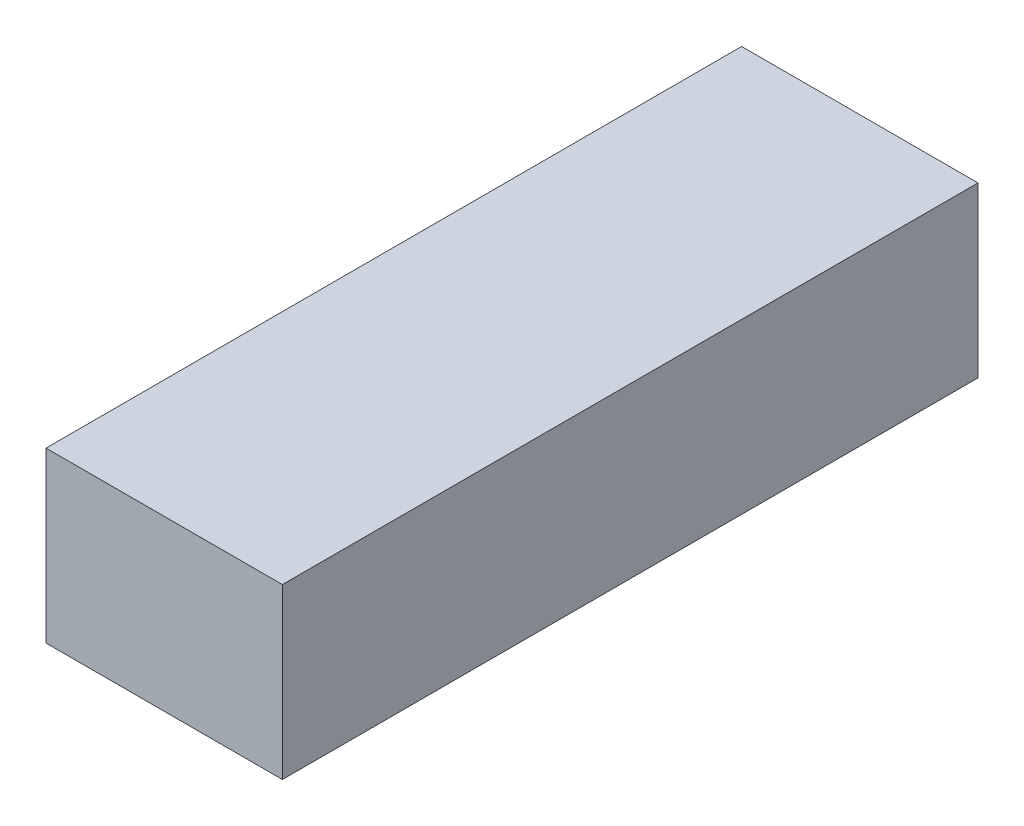
from build123d import *

# Parameters (mm, degrees)
SKETCH_1_W      = 35
SKETCH_1_H      = 25
EXTRUDE_1_DEPTH = 103


with BuildPart() as part:
    # 草图1 → 凸台-拉伸1 (new body)
    with BuildSketch(Plane.XY):
        with Locations((17.5, 12.5)):
            Rectangle(SKETCH_1_W, SKETCH_1_H)
    extrude(amount=EXTRUDE_1_DEPTH)


solid = part.part
